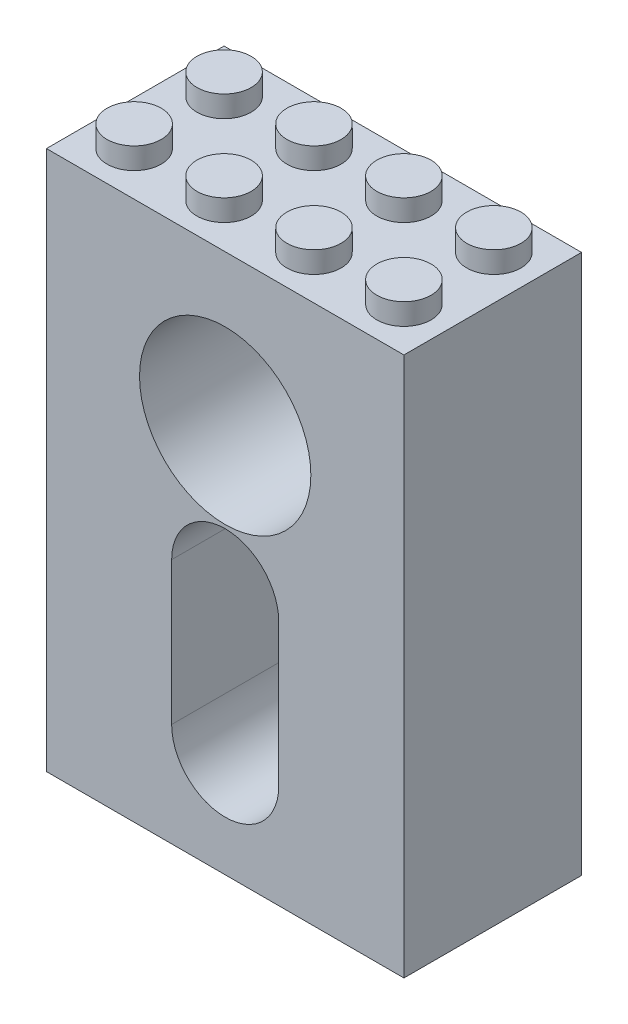
from build123d import *

# Parameters (mm, degrees)
SKETCH1_W           = 31.8
SKETCH1_H           = 48
BOSS_EXTRUDE1_DEPTH = 15.8
SKETCH2_R           = 7.62
CUT_EXTRUDE1_DEPTH  = 12.7
SKETCH3_R           = 2.77815
SKETCH3_R_2         = 1.8415
CUT_EXTRUDE2_DEPTH  = 12.7
CUT_EXTRUDE3_DEPTH  = 1.905
SKETCH5_R           = 2.41
BOSS_EXTRUDE2_DEPTH = 1.905
SKETCH6_W           = 29.36
SKETCH6_H           = 13.36
SKETCH6_R           = 3.26
CUT_EXTRUDE4_DEPTH  = 1.905


with BuildPart() as part:
    # Sketch1 → Boss-Extrude1 (new body)
    with BuildSketch(Plane.XY):
        Rectangle(SKETCH1_W, SKETCH1_H)
    extrude(amount=BOSS_EXTRUDE1_DEPTH)

    # Sketch2 → Cut-Extrude1 (cut)
    with BuildSketch(Plane.XY.offset(15.8)):
        with Locations((0, 10.6)):
            Circle(SKETCH2_R)
        with BuildLine():
            Line((4.7625, -2.1), (4.7625, -14.8))
            ThreePointArc((4.7625, -14.8), (0, -19.5625), (-4.7625, -14.8))
            Line((-4.7625, -14.8), (-4.7625, -2.1))
            ThreePointArc((-4.7625, -2.1), (0, 2.6625), (4.7625, -2.1))
        make_face()
    extrude(amount=-CUT_EXTRUDE1_DEPTH, mode=Mode.SUBTRACT)

    # Sketch3 → Cut-Extrude2 (cut)
    with BuildSketch(Plane(origin=(0, 0, 0), x_dir=(-1, 0, 0), z_dir=(0, 0, -1))):
        with Locations((0, 10.6)):
            Circle(SKETCH3_R)
        with Locations((0, -2.1)):
            Circle(SKETCH3_R_2)
        with Locations((0, -14.8)):
            Circle(SKETCH3_R_2)
    extrude(amount=-CUT_EXTRUDE2_DEPTH, mode=Mode.SUBTRACT)

    # Sketch4 → Cut-Extrude3 (cut)
    with BuildSketch(Plane(origin=(0, 0, 0), x_dir=(-1, 0, 0), z_dir=(0, 0, -1))):
        with BuildLine():
            Line((4.7625, -14.8), (4.7625, -2.1))
            ThreePointArc((4.7625, -2.1), (0, 2.6625), (-4.7625, -2.1))
            Line((-4.7625, -2.1), (-4.7625, -14.8))
            ThreePointArc((-4.7625, -14.8), (0, -19.5625), (4.7625, -14.8))
        make_face()
    extrude(amount=-CUT_EXTRUDE3_DEPTH, mode=Mode.SUBTRACT)

    # Sketch5 → Boss-Extrude2 (add)
    with BuildSketch(Plane(origin=(0, 24, 0), x_dir=(1, 0, 0), z_dir=(0, 1, 0))):
        with Locations((-12, -3.9)):
            Circle(SKETCH5_R)
        with Locations((-12, -11.9)):
            Circle(SKETCH5_R)
        with Locations((-4, -3.9)):
            Circle(SKETCH5_R)
        with Locations((-4, -11.9)):
            Circle(SKETCH5_R)
        with Locations((4, -3.9)):
            Circle(SKETCH5_R)
        with Locations((4, -11.9)):
            Circle(SKETCH5_R)
        with Locations((12, -3.9)):
            Circle(SKETCH5_R)
        with Locations((12, -11.9)):
            Circle(SKETCH5_R)
    extrude(amount=BOSS_EXTRUDE2_DEPTH)

    # Sketch6 → Cut-Extrude4 (cut)
    with BuildSketch(Plane.XZ.offset(24)):
        with Locations((0, 7.9)):
            Rectangle(SKETCH6_W, SKETCH6_H)
        with Locations((-8, 7.9)):
            Circle(SKETCH6_R, mode=Mode.SUBTRACT)
        with Locations((0, 7.9)):
            Circle(SKETCH6_R, mode=Mode.SUBTRACT)
        with Locations((8, 7.9)):
            Circle(SKETCH6_R, mode=Mode.SUBTRACT)
    extrude(amount=-CUT_EXTRUDE4_DEPTH, mode=Mode.SUBTRACT)


solid = part.part
